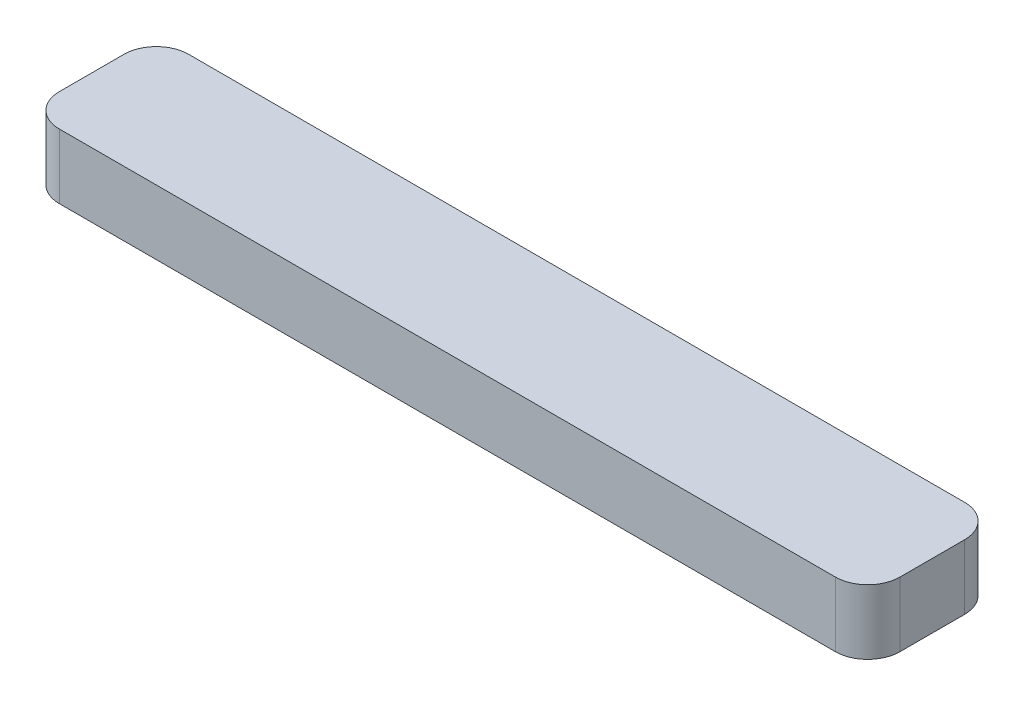
from build123d import *

# Parameters (mm, degrees)
BOSS_EXTRUDE1_DEPTH = 1


with BuildPart() as part:
    # Sketch2 → Boss-Extrude1 (new body)
    with BuildSketch(Plane(origin=(0, 0, 0), x_dir=(1, 0, 0), z_dir=(0, 1, 0))):
        with BuildLine():
            Line((-6, 1), (6, 1))
            ThreePointArc((6, 1), (6.353553391, 0.853553391), (6.5, 0.5))
            Line((6.5, 0.5), (6.5, -0.5))
            ThreePointArc((6.5, -0.5), (6.353553391, -0.853553391), (6, -1))
            Line((6, -1), (-6, -1))
            ThreePointArc((-6, -1), (-6.353553391, -0.853553391), (-6.5, -0.5))
            Line((-6.5, -0.5), (-6.5, 0.5))
            ThreePointArc((-6.5, 0.5), (-6.353553391, 0.853553391), (-6, 1))
        make_face()
    extrude(amount=BOSS_EXTRUDE1_DEPTH)


solid = part.part
